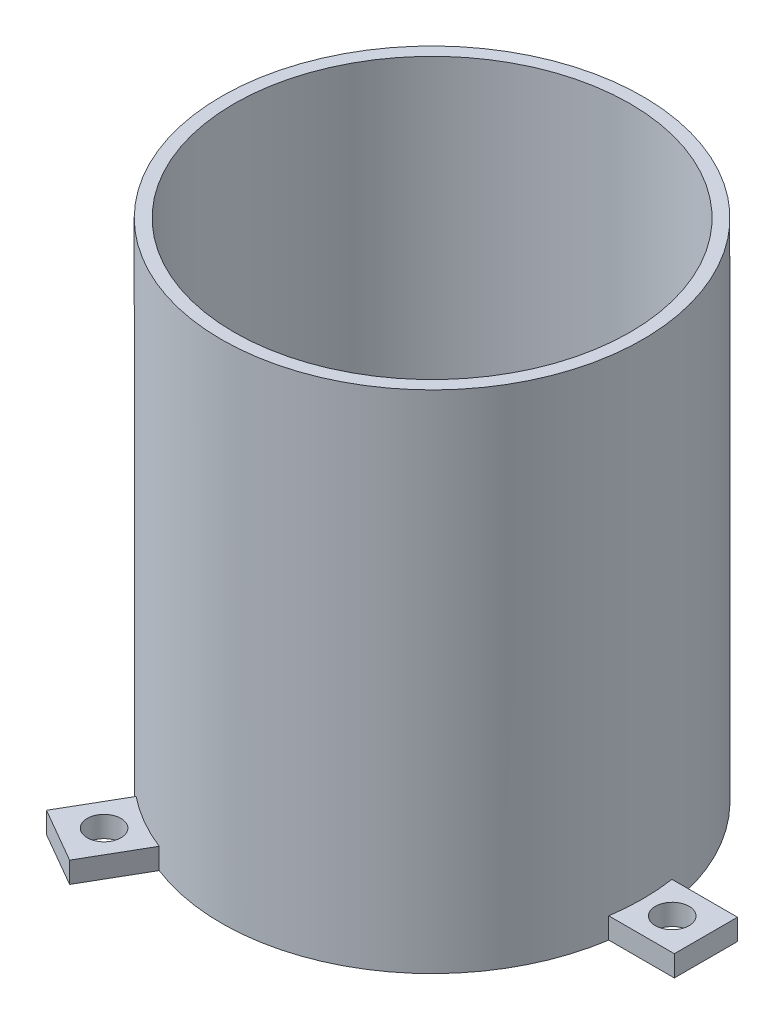
from build123d import *

# Parameters (mm, degrees)
SKETCH1_R           = 50
BOSS_EXTRUDE1_DEPTH = 120
SHELL1_T            = -3
SKETCH2_R           = 4
BOSS_EXTRUDE2_DEPTH = 5


with BuildPart() as part:
    # Sketch1 → Boss-Extrude1 (new body)
    with BuildSketch(Plane(origin=(0, 0, 0), x_dir=(1, 0, 0), z_dir=(0, 1, 0))):
        with Locations(Location((0, 0, 0), (0, 0, 270))):
            Circle(SKETCH1_R)
    extrude(amount=BOSS_EXTRUDE1_DEPTH)

    # Shell1
    shell1_openings = [part.faces().sort_by_distance(p)[0] for p in [
        (0, 120, 0),
    ]]
    offset(amount=SHELL1_T, openings=shell1_openings, kind=Kind.INTERSECTION)

    # Sketch2 → Boss-Extrude2 (add)
    with BuildSketch(Plane.XZ):
        with BuildLine():
            Line((49.434299833, 7.5), (65, 7.5))
            Line((65, 7.5), (65, -7.5))
            Line((65, -7.5), (49.434299833, -7.5))
            ThreePointArc((49.434299833, -7.5), (50, 0), (49.434299833, 7.5))
        make_face()
        with Locations(Location((57, 0, 0), (0, 0, 270))):
            Circle(SKETCH2_R, mode=Mode.SUBTRACT)
        with BuildLine():
            Line((-18.221959388, -46.561359474), (-26.004809472, -60.041651246))
            Line((-26.004809472, -60.041651246), (-38.995190528, -52.541651246))
            Line((-38.995190528, -52.541651246), (-31.212340445, -39.061359474))
            ThreePointArc((-31.212340445, -39.061359474), (-25, -43.301270189), (-18.221959388, -46.561359474))
        make_face()
        with Locations(Location((-28.5, -49.363448016, 0), (0, 0, 270))):
            Circle(SKETCH2_R, mode=Mode.SUBTRACT)
        with BuildLine():
            Line((-31.212340445, 39.061359474), (-38.995190528, 52.541651246))
            Line((-38.995190528, 52.541651246), (-26.004809472, 60.041651246))
            Line((-26.004809472, 60.041651246), (-18.221959388, 46.561359474))
            ThreePointArc((-18.221959388, 46.561359474), (-25, 43.301270189), (-31.212340445, 39.061359474))
        make_face()
        with Locations(Location((-28.5, 49.363448016, 0), (0, 0, 270))):
            Circle(SKETCH2_R, mode=Mode.SUBTRACT)
    extrude(amount=-BOSS_EXTRUDE2_DEPTH)


solid = part.part
